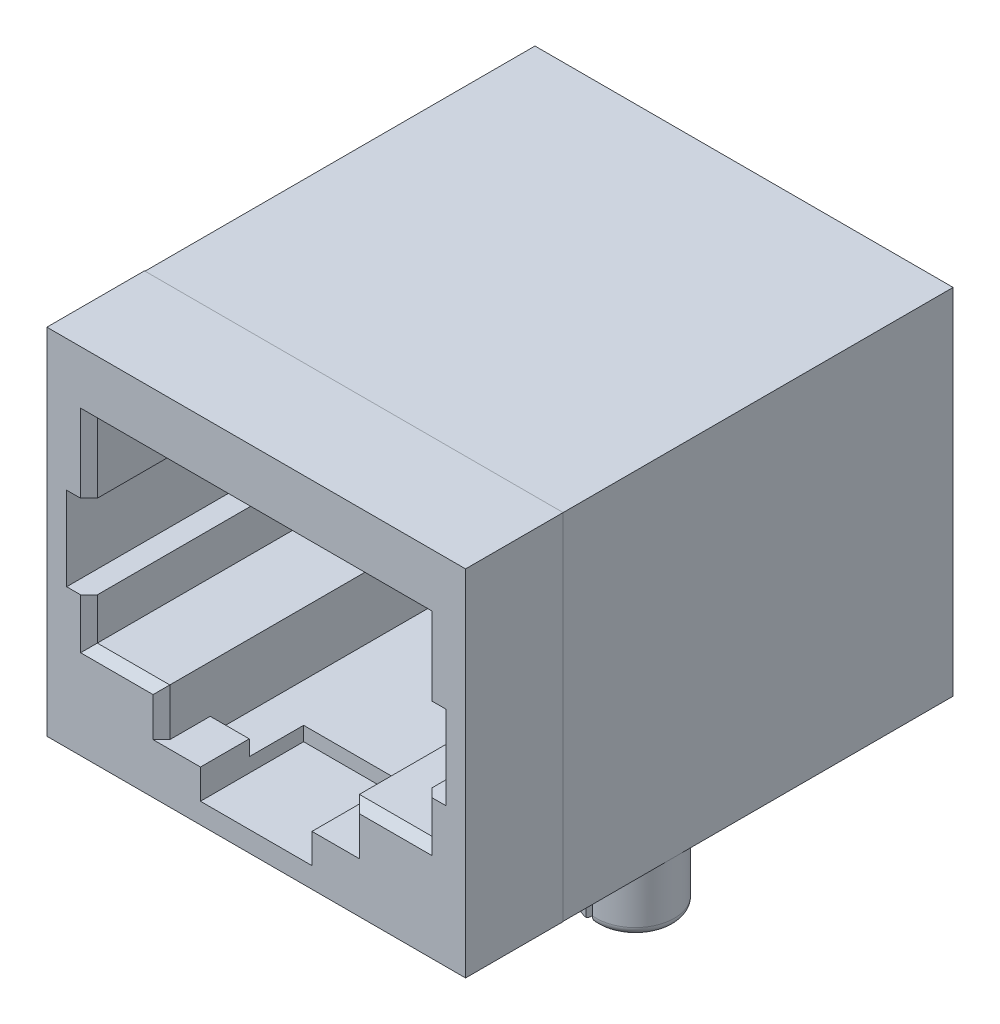
from build123d import *

# Parameters (mm, degrees)
SKETCH1_W                = 15
SKETCH1_H                = 17.5
EXTRUDE1_DEPTH           = 12.7
CUT_EXTRUDE1_DEPTH       = 11
SKETCH3_W                = 12
SKETCH3_H                = 7
CUT_EXTRUDE2_DEPTH       = 8.2
SKETCH4_W                = 4
SKETCH4_H                = 1.064395865
CUT_EXTRUDE3_DEPTH       = 3.7
SKETCH5_W                = 6.8
SKETCH5_H                = 1.403803501
CUT_EXTRUDE4_DEPTH       = 10.25
SKETCH6_W                = 0.8
SKETCH6_H                = 3
CUT_EXTRUDE5_DEPTH       = 12
CUT_EXTRUDE6_DEPTH       = 11.5
SKETCH8_W                = 13.4
SKETCH8_H                = 6
CUT_EXTRUDE7_DEPTH       = 1.746196499
CHAMFER1_SIZE            = 0.3
EXTRUDE2_DEPTH           = 3.5
SKETCH10_R               = 1.4
EXTRUDE3_DEPTH           = 2.2
EXTRUDE4_DEPTH           = 0.7
EXTRUDE4_DRAFT           = 25
EXTRUDE4_PROFILE_2_DEPTH = 0.7
EXTRUDE4_PROFILE_2_DRAFT = 25
CUT_EXTRUDE8_DEPTH       = 18.161197511
FILLET1_R                = 0.3
SKETCH16_W               = 10.3
SKETCH16_H               = 4.02079932
CUT_EXTRUDE9_DEPTH       = 0.18
SKETCH15_R               = 0.15
LPATTERN1_COUNT          = 8
LPATTERN1_PITCH          = 1.05


with BuildPart() as part:
    # Sketch1 → Extrude1 (new body)
    with BuildSketch(Plane(origin=(0, 0, 0), x_dir=(1, 0, 0), z_dir=(0, 1, 0))):
        Rectangle(SKETCH1_W, SKETCH1_H)
    extrude(amount=EXTRUDE1_DEPTH)

    # Sketch2 → Cut-Extrude1 (cut)
    with BuildSketch(Plane.XY.offset(8.75)):
        Polygon((-6, 10.5), (6, 10.5), (6, 8), (6.8, 8), (6.8, 5), (6, 5), (6, 4.5), (3.4, 4.5), (3.4, 1.8), (-3.4, 1.8), (-3.4, 4.5), (-6, 4.5), (-6, 5), (-6.8, 5), (-6.8, 8), (-6, 8), align=None)
    extrude(amount=-CUT_EXTRUDE1_DEPTH, mode=Mode.SUBTRACT)

    # Sketch3 → Cut-Extrude2 (cut)
    with BuildSketch(Plane.XY.offset(8.75)):
        with Locations((0, 7)):
            Rectangle(SKETCH3_W, SKETCH3_H)
    extrude(amount=-CUT_EXTRUDE2_DEPTH, mode=Mode.SUBTRACT)

    # Sketch4 → Cut-Extrude3 (cut)
    with BuildSketch(Plane.XY.offset(8.75)):
        with Locations((0, 1.267802067)):
            Rectangle(SKETCH4_W, SKETCH4_H)
    extrude(amount=-CUT_EXTRUDE3_DEPTH, mode=Mode.SUBTRACT)

    # Sketch5 → Cut-Extrude4 (cut)
    with BuildSketch(Plane.XY.offset(7)):
        with Locations((0, 1.94809825)):
            Rectangle(SKETCH5_W, SKETCH5_H)
    extrude(amount=-CUT_EXTRUDE4_DEPTH, mode=Mode.SUBTRACT)

    # Sketch6 → Cut-Extrude5 (cut)
    with BuildSketch(Plane.XY.offset(8.75)):
        with Locations((-6.4, 6.5)):
            Rectangle(SKETCH6_W, SKETCH6_H)
        with Locations((6.4, 6.5)):
            Rectangle(SKETCH6_W, SKETCH6_H)
    extrude(amount=-CUT_EXTRUDE5_DEPTH, mode=Mode.SUBTRACT)

    # Sketch7 → Cut-Extrude6 (cut)
    with BuildSketch(Plane.XY.offset(8.75)):
        Polygon((-6, 5.5), (6, 5.5), (6, 4.5), (3.4, 4.5), (3.4, 2.65), (-3.4, 2.65), (-3.4, 4.5), (-6, 4.5), align=None)
    extrude(amount=-CUT_EXTRUDE6_DEPTH, mode=Mode.SUBTRACT)

    # Sketch8 → Cut-Extrude7 (cut)
    with BuildSketch(Plane.XZ):
        with Locations((0, -5.75)):
            Rectangle(SKETCH8_W, SKETCH8_H)
    extrude(amount=-CUT_EXTRUDE7_DEPTH, mode=Mode.SUBTRACT)

    # Chamfer1
    chamfer1_edges = [part.edges().sort_by_distance(p)[0] for p in [
        (-6, 9.25, 8.75),
        (-6, 4.25, 8.75),
        (3.4, 2.65, 8.75),
        (6, 4.25, 8.75),
        (6, 9.25, 8.75),
        (0, 10.5, 8.75),
        (-3.4, 2.65, 8.75),
        (4.7, 3.5, 8.75),
        (-4.7, 3.5, 8.75),
    ]]
    chamfer(chamfer1_edges, length=CHAMFER1_SIZE)

    # Sketch9 → Extrude2 (add)
    with BuildSketch(Plane.XY.offset(8.75)):
        Polygon((7.5, 12.7), (7.5, 0), (7.51, 0), (7.51, 12.71), (-7.51, 12.71), (-7.51, 0), (-7.5, 0), (-7.5, 12.7), align=None)
    extrude(amount=-EXTRUDE2_DEPTH)

    # Sketch10 → Extrude3 (add)
    with BuildSketch(Plane.XZ):
        with Locations(Location((-6.1, 1.25, 0), (0, 0, 180))):
            Circle(SKETCH10_R)
        with Locations((6.1, 1.25)):
            Circle(SKETCH10_R)
    extrude(amount=EXTRUDE3_DEPTH)


with BuildPart() as extrude4_tool:
    # Sketch12 → Extrude4 (with draft: the straight prism first)
    with BuildSketch(Plane.XZ.offset(2.2)):
        with BuildLine():
            Line((-5.65, 2.575707358), (-5.65, -0.075707358))
            ThreePointArc((-5.65, -0.075707358), (-4.7, 1.25), (-5.65, 2.575707358))
        make_face()
    extrude(amount=-EXTRUDE4_DEPTH)
    # Extrude4: the draft: its side faces are tilted about the plane it starts from
    extrude4_sides = [extrude4_tool.faces().sort_by_distance(p)[0] for p in [
        (-4.7, -1.85, 1.25),
        (-5.65, -1.85, 1.25),
    ]]
    draft(extrude4_sides, Plane.XZ.offset(2.2), EXTRUDE4_DRAFT)


with BuildPart() as part_1:
    add(part.part)

    # Extrude4: add extrude4_tool
    add(extrude4_tool.part)


with BuildPart() as extrude4_profile_2_tool:
    # Sketch12 → Extrude4 profile 2 (with draft: the straight prism first)
    with BuildSketch(Plane.XZ.offset(2.2)):
        with BuildLine():
            Line((5.65, -0.075707358), (5.65, 2.575707358))
            ThreePointArc((5.65, 2.575707358), (4.7, 1.25), (5.65, -0.075707358))
        make_face()
    extrude(amount=-EXTRUDE4_PROFILE_2_DEPTH)
    # Extrude4 profile 2: the draft: its side faces are tilted about the plane it starts from
    extrude4_profile_2_sides = [extrude4_profile_2_tool.faces().sort_by_distance(p)[0] for p in [
        (5.65, -1.85, 1.25),
        (4.7, -1.85, 1.25),
    ]]
    draft(extrude4_profile_2_sides, Plane.XZ.offset(2.2), EXTRUDE4_PROFILE_2_DRAFT)


with BuildPart() as part_2:
    add(part_1.part)

    # Extrude4 profile 2: add extrude4_profile_2_tool
    add(extrude4_profile_2_tool.part)

    # Sketch11 → Cut-Extrude8 (cut, through all)
    with BuildSketch(Plane.XZ):
        with BuildLine():
            Line((-5.95, 3.644787429), (-5.65, 3.644787429))
            Line((-5.65, 3.644787429), (-4.310937557, 3.644787429))
            Line((-4.310937557, 3.644787429), (-4.310937557, 2.575707358))
            Line((-4.310937557, 2.575707358), (-5.65, 2.575707358))
            Line((-5.65, 2.575707358), (-5.65, -0.075707358))
            Line((-5.65, -0.075707358), (-4.310937557, -0.075707358))
            Line((-4.310937557, -0.075707358), (-4.310937557, -0.748928924))
            Line((-4.310937557, -0.748928924), (-5.65, -0.748928924))
            Line((-5.65, -0.748928924), (-5.95, -0.748928924))
            Line((-5.95, -0.748928924), (-5.95, -0.637475435))
            ThreePointArc((-5.95, -0.637475435), (-7.993426396, 1.25), (-5.95, 3.137475435))
            Line((-5.95, 3.137475435), (-5.95, 3.644787429))
        make_face()
        with BuildLine():
            Line((-5.95, 2.641941091), (-5.95, -0.141941091))
            ThreePointArc((-5.95, -0.141941091), (-7.5, 1.25), (-5.95, 2.641941091))
        make_face(mode=Mode.SUBTRACT)
        with BuildLine():
            Line((5.65, 3.644787429), (5.95, 3.644787429))
            Line((5.95, 3.644787429), (5.95, 3.50541997))
            ThreePointArc((5.95, 3.50541997), (8.360402451, 1.25), (5.95, -1.00541997))
            Line((5.95, -1.00541997), (5.95, -1.880643742))
            Line((5.95, -1.880643742), (5.65, -1.880643742))
            Line((5.65, -1.880643742), (4.392807045, -1.880643742))
            Line((4.392807045, -1.880643742), (4.392807045, -0.075707358))
            Line((4.392807045, -0.075707358), (5.65, -0.075707358))
            Line((5.65, -0.075707358), (5.65, 2.575707358))
            Line((5.65, 2.575707358), (4.392807045, 2.575707358))
            Line((4.392807045, 2.575707358), (4.392807045, 3.644787429))
            Line((4.392807045, 3.644787429), (5.65, 3.644787429))
        make_face()
        with BuildLine():
            Line((5.95, 2.641941091), (5.95, -0.141941091))
            ThreePointArc((5.95, -0.141941091), (7.5, 1.25), (5.95, 2.641941091))
        make_face(mode=Mode.SUBTRACT)
    extrude(amount=CUT_EXTRUDE8_DEPTH, mode=Mode.SUBTRACT)

    # Fillet1
    fillet1_edges = [part_2.edges().sort_by_distance(p)[0] for p in [
        (7.035414347, -2.2, 0.208366667),
        (-7.035414347, -2.2, 0.208366667),
        (4.7, -2.2, 1.25),
        (-4.7, -2.2, 1.25),
    ]]
    fillet(fillet1_edges, radius=FILLET1_R)

    # Sketch16 → Cut-Extrude9 (cut, symmetric)
    with BuildSketch(Plane(origin=(-3.7, 0, 0), x_dir=(0, 0, -1), z_dir=(1, 0, 0))):
        with Locations((-2.35, 9.03576247)):
            Rectangle(SKETCH16_W, SKETCH16_H)
    cut_extrude9 = extrude(amount=CUT_EXTRUDE9_DEPTH, both=True, mode=Mode.SUBTRACT)

    # Sweep2: sweep along a path in Sketch13
    with BuildLine(Plane(origin=(-3.7, 0, 0), x_dir=(0, 0, -1), z_dir=(1, 0, 0))) as sweep2_path:
        Line((3.965955208, 7.437679072), (2.25, 7.437679072))
        Line((2.25, 7.437679072), (-6.809105765, 10.5))
        ThreePointArc((-6.809105765, 10.5), (-7.034210423, 10.81371206), (-6.809105765, 11.127424121))
    # Sketch15 → Sweep2 (sweep)
    with BuildSketch(Plane(origin=(-3.7, 11.127424121, 6.809105765), x_dir=(-1, 0, 0), z_dir=(0, 0.32023605668883565, -0.947337779251089))):
        Circle(SKETCH15_R)
    sweep2 = sweep(path=sweep2_path.line, transition=Transition.RIGHT)

    # LPattern1: Cut-Extrude9, Sweep2 ×8
    with Locations(*[(i * LPATTERN1_PITCH, 0, 0) for i in range(1, LPATTERN1_COUNT)]):
        add(cut_extrude9, mode=Mode.SUBTRACT)
        add(sweep2)


solid = part_2.part
